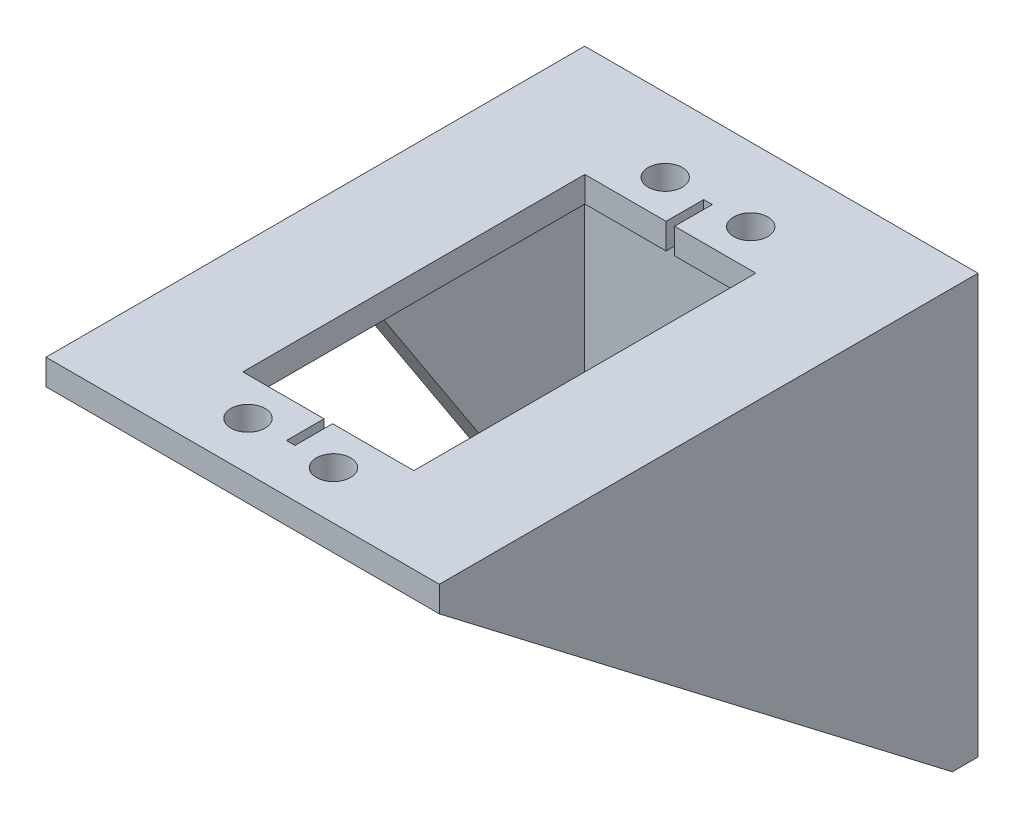
from build123d import *

# Parameters (mm, degrees)
SKETCH1_W                = 46
SKETCH1_H                = 46
SKETCH1_R                = 3
SKETCH1_R_2              = 0.75
BOSS_EXTRUDE1_DEPTH      = 3
SKETCH2_W                = 46
SKETCH2_H                = 3
BOSS_EXTRUDE2_DEPTH      = 60
BOSS_EXTRUDE2_DEPTH_BACK = 3
SKETCH3_R                = 2
CUT_EXTRUDE1_DEPTH       = 10
SKETCH4_W                = 3
SKETCH4_H                = 60
SKETCH4_H_2              = 30
BOSS_EXTRUDE3_DEPTH      = 46
CUT_EXTRUDE2_DEPTH       = 46
CUT_EXTRUDE2_DEPTH_BACK  = 46
CUT_EXTRUDE3_DEPTH       = 15
SKETCH7_W                = 4.5
SKETCH7_H                = 3
CUT_EXTRUDE4_DEPTH       = 10


with BuildPart() as part:
    # Sketch1 → Boss-Extrude1 (new body)
    with BuildSketch(Plane.XY):
        with Locations((23, 23)):
            Rectangle(SKETCH1_W, SKETCH1_H)
        with Locations((23, 23)):
            Circle(SKETCH1_R, mode=Mode.SUBTRACT)
        with Locations((30, 23)):
            Circle(SKETCH1_R_2, mode=Mode.SUBTRACT)
        with Locations((23, 30)):
            Circle(SKETCH1_R_2, mode=Mode.SUBTRACT)
        with Locations((16, 23)):
            Circle(SKETCH1_R_2, mode=Mode.SUBTRACT)
        with Locations((23, 16)):
            Circle(SKETCH1_R_2, mode=Mode.SUBTRACT)
    extrude(amount=BOSS_EXTRUDE1_DEPTH)

    # Sketch2 → Boss-Extrude2 (add, two sides)
    with BuildSketch(Plane.XY.offset(3)) as boss_extrude2_sk:
        with Locations((23, 47.5)):
            Rectangle(SKETCH2_W, SKETCH2_H)
    extrude(amount=BOSS_EXTRUDE2_DEPTH)
    extrude(boss_extrude2_sk.sketch, amount=-BOSS_EXTRUDE2_DEPTH_BACK)

    # Sketch3 → Cut-Extrude1 (cut)
    with BuildSketch(Plane(origin=(0, 46, 0), x_dir=(-1, 0, 0), z_dir=(0, -1, 0))):
        with Locations((-18, -8.581054425)):
            Circle(SKETCH3_R)
        with Locations((-18, -57.381054425)):
            Circle(SKETCH3_R)
        with Locations((-28, -57.381054425)):
            Circle(SKETCH3_R)
        with Locations((-28, -8.581054425)):
            Circle(SKETCH3_R)
        Polygon((-22.5, -12.981054425), (-22.5, -8.581054425), (-23.5, -8.581054425), (-23.5, -12.981054425), (-33, -12.981054425), (-33, -52.981054425), (-23.5, -52.981054425), (-23.5, -57.381054425), (-22.5, -57.381054425), (-22.5, -52.981054425), (-13, -52.981054425), (-13, -12.981054425), align=None)
    extrude(amount=-CUT_EXTRUDE1_DEPTH, mode=Mode.SUBTRACT)

    # Sketch4 → Boss-Extrude3 (add)
    with BuildSketch(Plane(origin=(0, 46, 0), x_dir=(-1, 0, 0), z_dir=(0, -1, 0))):
        with Locations((-44.5, -33)):
            Rectangle(SKETCH4_W, SKETCH4_H)
        with Locations((-1.5, -18)):
            Rectangle(SKETCH4_W, SKETCH4_H_2)
    extrude(amount=BOSS_EXTRUDE3_DEPTH)

    # Sketch5 → Cut-Extrude2 (cut, two sides)
    with BuildSketch(Plane.ZY.offset(-43)) as cut_extrude2_sk:
        Polygon((63, 46), (3, 0), (63, 0), align=None)
    extrude(amount=CUT_EXTRUDE2_DEPTH, mode=Mode.SUBTRACT)
    extrude(cut_extrude2_sk.sketch, amount=-CUT_EXTRUDE2_DEPTH_BACK, mode=Mode.SUBTRACT)

    # Sketch6 → Cut-Extrude3 (cut)
    with BuildSketch(Plane.ZY):
        Polygon((3, 0), (33, 46), (33, 23), align=None)
    extrude(amount=-CUT_EXTRUDE3_DEPTH, mode=Mode.SUBTRACT)

    # Sketch7 → Cut-Extrude4 (cut)
    with BuildSketch(Plane.XY.offset(3)):
        with Locations((36.25, 38.5)):
            Rectangle(SKETCH7_W, SKETCH7_H)
        with Locations((31.75, 38.5)):
            Rectangle(SKETCH7_W, SKETCH7_H)
    extrude(amount=-CUT_EXTRUDE4_DEPTH, mode=Mode.SUBTRACT)


solid = part.part
